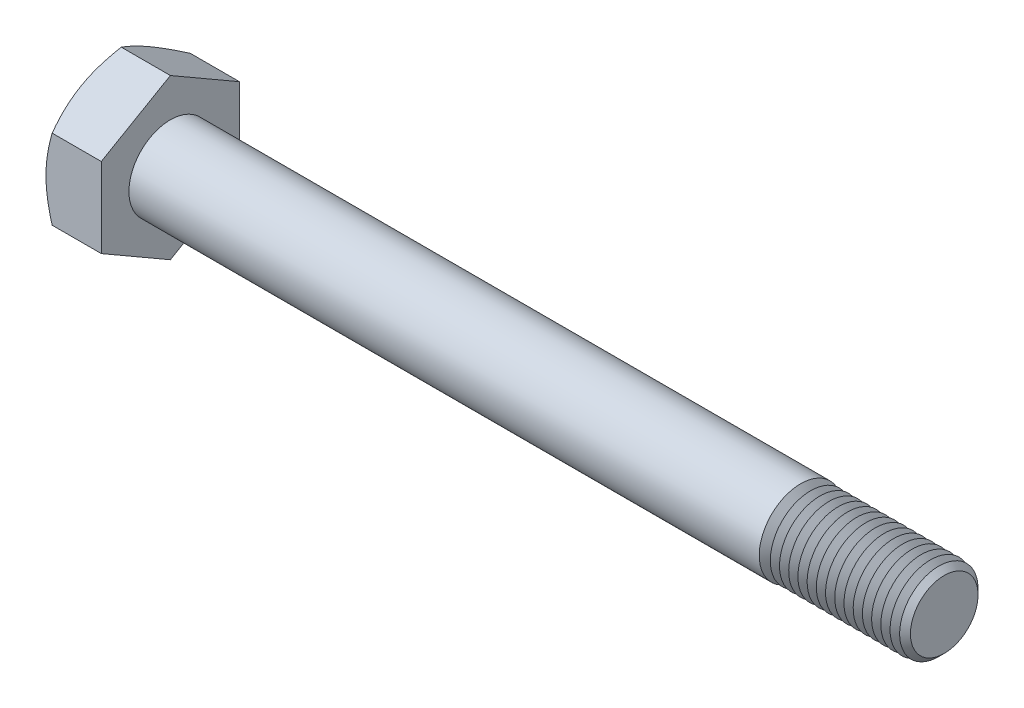
from build123d import *

# Parameters (mm, degrees)
BASEHEAD_DEPTH  = 4
THDSCHPAT_COUNT = 15
THDSCHPAT_PITCH = 0.666666667


with BuildPart() as part:
    # Sketch1 → BaseHead (new body)
    with BuildSketch(Plane(origin=(0, 0, 0), x_dir=(0, 0, -1), z_dir=(1, 0, 0))):
        Polygon((5, 2.886751346), (5, -2.886751346), (0, -5.773502692), (-5, -2.886751346), (-5, 2.886751346), (0, 5.773502692), align=None)
    extrude(amount=BASEHEAD_DEPTH)

    # BodySke → BaseBody (revolve)
    with BuildSketch(Plane.XY):
        Polygon((0, 0), (60, 0), (60, 2.4455), (59.4455, 3), (0, 3), align=None)
    revolve(axis=Axis((0, 0, 0), (1, 0, 0)))

    # Sketch3 → HeadChamfer (revolve, cut)
    with BuildSketch(Plane.XY):
        Polygon((0, 5), (3.333333333, 10.773502692), (3.333333333, 15.773502692), (-10, 15.773502692), (-10, 5), align=None)
    revolve(axis=Axis((0, 0, 0), (1, 0, 0)), mode=Mode.SUBTRACT)

    # ThdSchSke → ThreadSchematic (revolve, cut)
    with BuildSketch(Plane.XY):
        Polygon((50, -2.4455), (49.61173492, -3), (49.61173492, -3.75), (50.38826508, -3.75), (50.38826508, -3), align=None)
    threadschematic = revolve(axis=Axis((-3.175, 0, 0), (1, 0, 0)), mode=Mode.SUBTRACT)

    # ThdSchPat: ThreadSchematic ×15
    with Locations(*[(i * THDSCHPAT_PITCH, 0, 0) for i in range(1, THDSCHPAT_COUNT)]):
        add(threadschematic, mode=Mode.SUBTRACT)


solid = part.part
